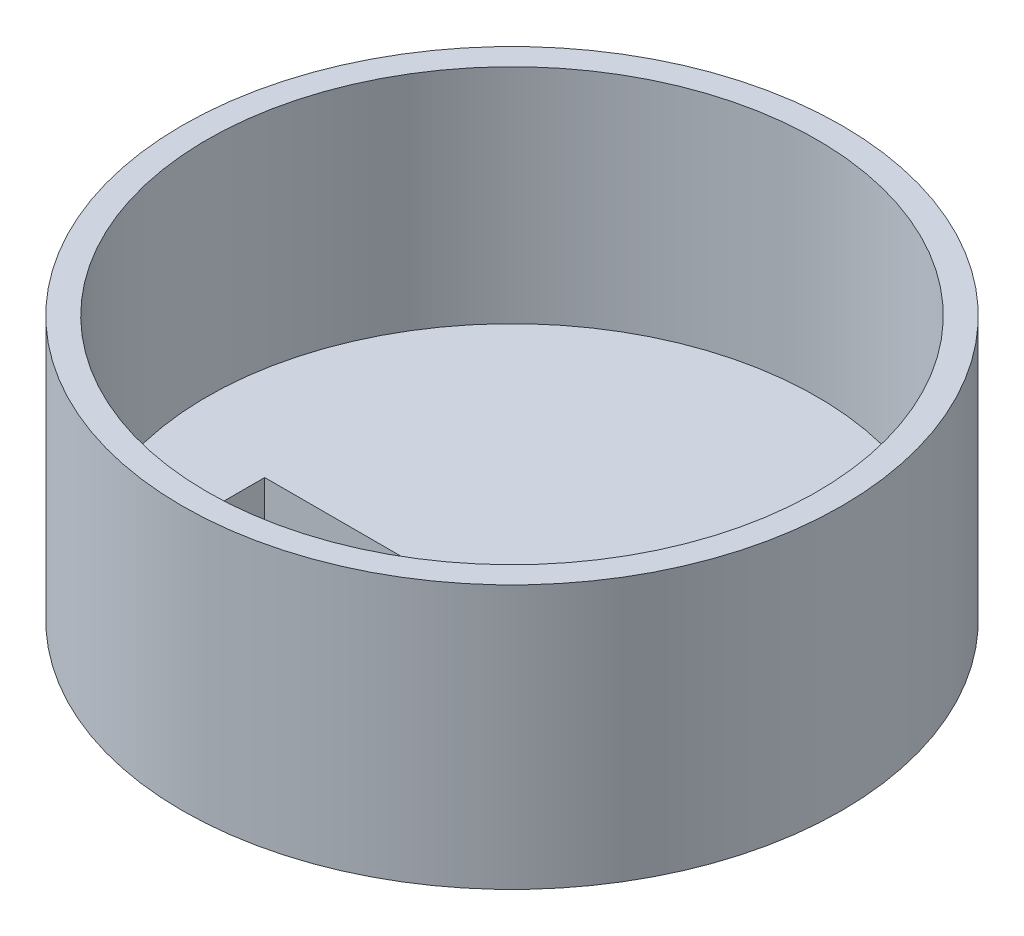
from build123d import *

# Parameters (mm, degrees)
SKETCH2_R               = 40
BOSS_EXTRUDE1_DEPTH     = 30
SKETCH3_R               = 37
CUT_EXTRUDE1_DEPTH      = 27
SKETCH4_W               = 20
SKETCH4_H               = 10
CUT_EXTRUDE2_DEPTH      = 10
CUT_EXTRUDE2_DEPTH_BACK = 10
BOSS_EXTRUDE2_DEPTH     = 2
BOSS_EXTRUDE3_DEPTH     = 1
CUT_EXTRUDE3_DEPTH      = 2
SKETCH8_R               = 40
SKETCH8_R_2             = 39
BOSS_EXTRUDE4_DEPTH     = 2
SKETCH10_W              = 23
SKETCH10_H              = 15
BOSS_EXTRUDE5_DEPTH     = 1
SKETCH11_W              = 20
SKETCH11_H              = 10
CUT_EXTRUDE5_DEPTH      = 3.0000001


with BuildPart() as part:
    # Sketch2 → Boss-Extrude1 (new body)
    with BuildSketch(Plane(origin=(0, 0, 0), x_dir=(1, 0, 0), z_dir=(0, 1, 0))):
        Circle(SKETCH2_R)
    extrude(amount=BOSS_EXTRUDE1_DEPTH)

    # Sketch3 → Cut-Extrude1 (cut)
    with BuildSketch(Plane(origin=(0, 30, 0), x_dir=(1, 0, 0), z_dir=(0, 1, 0))):
        Circle(SKETCH3_R)
    extrude(amount=-CUT_EXTRUDE1_DEPTH, mode=Mode.SUBTRACT)

    # Sketch4 → Cut-Extrude2 (cut, two sides)
    with BuildSketch(Plane.XZ) as cut_extrude2_sk:
        with Locations((15, 10)):
            Rectangle(SKETCH4_W, SKETCH4_H)
        with Locations((-15, 10)):
            Rectangle(SKETCH4_W, SKETCH4_H)
    extrude(amount=CUT_EXTRUDE2_DEPTH, mode=Mode.SUBTRACT)
    extrude(cut_extrude2_sk.sketch, amount=-CUT_EXTRUDE2_DEPTH_BACK, mode=Mode.SUBTRACT)

    # Sketch5 → Boss-Extrude2 (add)
    with BuildSketch(Plane.XZ):
        with BuildLine():
            add(Edge.make_bspline(
                [(-25, -5.507001786), (-23.36255757, -4.074108954), (0.0904347, -24.367910319), (37.697617146, 8.431321909), (0.307174997, -46.775296756), (-27.041712382, -7.293663096), (-25, -5.507001786)],
                knots=[0, 0, 0, 0, 0.224585643, 0.445237285, 0.719966161, 1, 1, 1, 1], degree=3))
        make_face()
    extrude(amount=BOSS_EXTRUDE2_DEPTH)

    # Sketch6 → Boss-Extrude3 (add)
    with BuildSketch(Plane.XZ):
        with BuildLine():
            add(Edge.make_bspline(
                [(2.585668023, 14.344301178), (1.364274466, 8.534441637), (-0.198470948, -2.108647296), (13.670391798, 0.501799815), (20.602168668, 0.456955562), (30.778687717, -1.043300206), (29.853246715, 6.729511175), (29.656614254, 12.18046735), (31.446966251, 17.236483626), (33.097693762, 21.90138397), (27.545293783, 26.646632176), (19.038873402, 21.271598157), (9.311187888, 23.975267805), (-0.090668901, 23.093852031), (-9.384308644, 23.925916917), (-19.130851036, 20.634216677), (-27.265477125, 26.40982217), (-33.298679343, 21.748921797), (-31.44206182, 16.75455886), (-30.823772547, 11.524258891), (-29.200430287, 6.23346714), (-31.080690058, -0.9099549), (-24.819919128, 0.240703401), (-19.147838271, 0.946963346), (-12.043202172, 0.224484749), (-0.603012827, -1.589466422), (-0.411714134, 10.001917312), (-2.896511425, 18.393397144), (3.532722354, 18.602264586), (2.86794465, 15.687019537), (2.585668023, 14.344301178)],
                knots=[0, 0, 0, 0, 0.071644683, 0.112352982, 0.167635857, 0.200467621, 0.225175545, 0.260861667, 0.287096675, 0.305438817, 0.328540716, 0.37335304, 0.434051313, 0.473333742, 0.513734662, 0.573284024, 0.616414278, 0.643022173, 0.658048675, 0.690377742, 0.72129713, 0.748243778, 0.765833783, 0.795666761, 0.841017233, 0.87409781, 0.945437547, 0.962596859, 0.983442176, 1, 1, 1, 1], degree=3))
        make_face()
    extrude(amount=BOSS_EXTRUDE3_DEPTH)

    # Sketch7 → Cut-Extrude3 (cut)
    with BuildSketch(Plane.XZ.offset(2)):
        with BuildLine():
            add(Edge.make_bspline(
                [(0, -17.914985591), (11.297270493, -17.91132759), (35.185394911, 4.982717635), (-0.084360802, -39.064515174), (-35.35897002, 5.247835741), (-11.369061694, -17.918666838), (0, -17.914985591)],
                knots=[0, 0, 0, 0, 0.235957957, 0.498457739, 0.762542592, 1, 1, 1, 1], degree=3))
        make_face()
    extrude(amount=-CUT_EXTRUDE3_DEPTH, mode=Mode.SUBTRACT)

    # Sketch8 → Boss-Extrude4 (add)
    with BuildSketch(Plane.XZ):
        Circle(SKETCH8_R)
        Circle(SKETCH8_R_2, mode=Mode.SUBTRACT)
    extrude(amount=BOSS_EXTRUDE4_DEPTH)

    # Sketch10 → Boss-Extrude5 (add)
    with BuildSketch(Plane.XZ.offset(1)):
        with Locations((-15, 10)):
            Rectangle(SKETCH10_W, SKETCH10_H)
        with Locations((15, 10)):
            Rectangle(SKETCH10_W, SKETCH10_H)
    extrude(amount=BOSS_EXTRUDE5_DEPTH)

    # Sketch11 → Cut-Extrude5 (cut, through all)
    with BuildSketch(Plane(origin=(0, 0, 0), x_dir=(1, 0, 0), z_dir=(0, 1, 0))):
        with Locations((15, -10)):
            Rectangle(SKETCH11_W, SKETCH11_H)
        with Locations((-15, -10)):
            Rectangle(SKETCH11_W, SKETCH11_H)
    extrude(amount=-CUT_EXTRUDE5_DEPTH, mode=Mode.SUBTRACT)


solid = part.part
